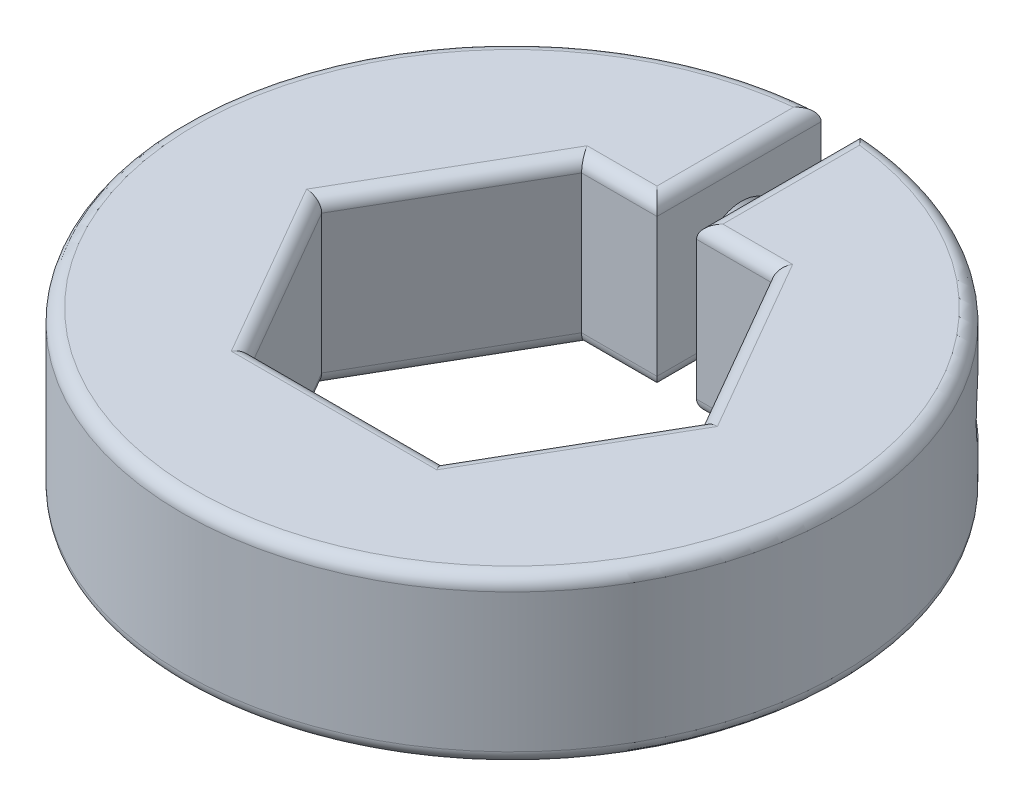
from build123d import *

# Parameters (mm, degrees)
SKETCH1_R               = 12.7
BOSS_EXTRUDE1_DEPTH     = 6.35
CUT_EXTRUDE1_DEPTH      = 0.762
CUT_EXTRUDE1_DEPTH_BACK = 0.762
SKETCH2_W               = 16.521892969
SKETCH2_H               = 16.064378343
CUT_EXTRUDE2_DEPTH      = 20.566245015
CUT_EXTRUDE2_DEPTH_BACK = 20.566245015
SKETCH3_R               = 1.450011988
FILLET1_R               = 0.508


with BuildPart() as part:
    # Sketch1 → Boss-Extrude1 (new body)
    with BuildSketch(Plane(origin=(0, 0, 0), x_dir=(1, 0, 0), z_dir=(0, 1, 0))):
        Circle(SKETCH1_R)
        Polygon((7.332348419, 0), (3.666174209, 6.35), (-3.666174209, 6.35), (-7.332348419, 0), (-3.666174209, -6.35), (3.666174209, -6.35), align=None, mode=Mode.SUBTRACT)
    extrude(amount=BOSS_EXTRUDE1_DEPTH)

    # Sketch2 → Cut-Extrude1 (cut, two sides: drawn at the far end of the back side and taken through both)
    with BuildSketch(Plane(origin=(0, 0, 0), x_dir=(0, 0, -1), z_dir=(1, 0, 0)).offset(-CUT_EXTRUDE1_DEPTH_BACK)):
        with Locations((10.843461422, 3.411156181)):
            Rectangle(SKETCH2_W, SKETCH2_H)
    extrude(amount=CUT_EXTRUDE1_DEPTH + CUT_EXTRUDE1_DEPTH_BACK, mode=Mode.SUBTRACT)

    # Sketch3 → Cut-Extrude2 (cut, two sides: drawn at the far end of the back side and taken through both)
    with BuildSketch(Plane.ZY.offset(-0.762).offset(-CUT_EXTRUDE2_DEPTH_BACK)):
        with Locations((-9.609846494, 3.271635)):
            Circle(SKETCH3_R)
    extrude(amount=CUT_EXTRUDE2_DEPTH + CUT_EXTRUDE2_DEPTH_BACK, mode=Mode.SUBTRACT)

    # Fillet1
    fillet1_edges = [part.edges().sort_by_distance(p)[0] for p in [
        (5.499261314, 0, -3.175),
        (5.499261314, 0, 3.175),
        (0, 0, 6.35),
        (-5.499261314, 0, 3.175),
        (-5.499261314, 0, -3.175),
        (-2.214087105, 0, -6.35),
        (-0.762, 0, -9.513559694),
        (-8.706681343, 0, 9.245739559),
        (0.762, 0, -9.513559694),
        (2.214087105, 0, -6.35),
        (-8.706681343, 6.35, 9.245739559),
        (-0.762, 6.35, -9.513559694),
        (-2.214087105, 6.35, -6.35),
        (-5.499261314, 6.35, -3.175),
        (-5.499261314, 6.35, 3.175),
        (0, 6.35, 6.35),
        (5.499261314, 6.35, 3.175),
        (5.499261314, 6.35, -3.175),
        (2.214087105, 6.35, -6.35),
        (0.762, 6.35, -9.513559694),
    ]]
    fillet(fillet1_edges, radius=FILLET1_R)


solid = part.part
